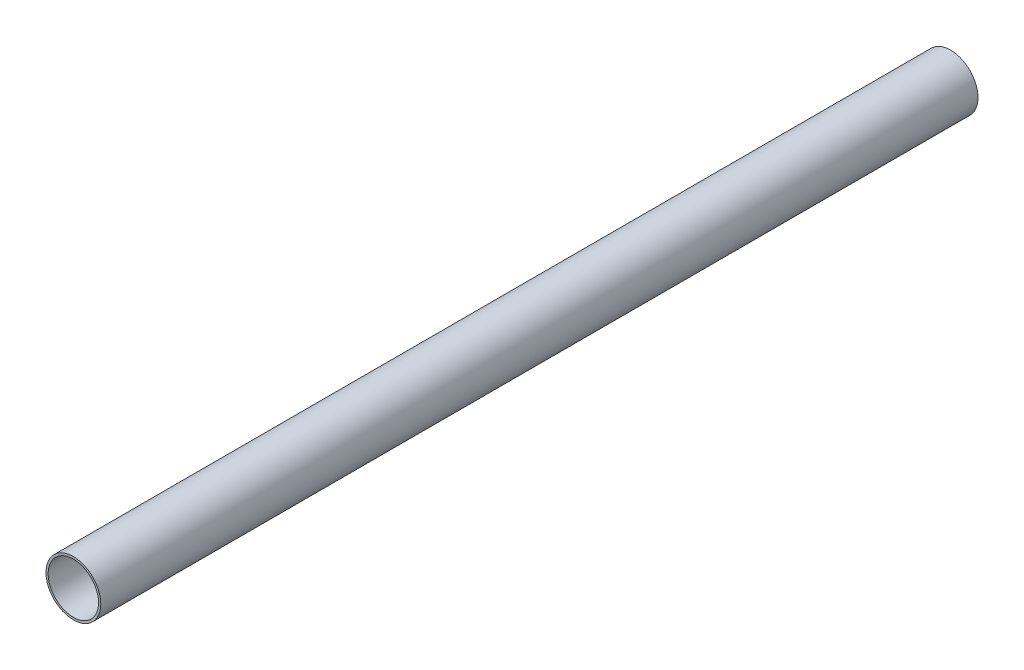
from build123d import *

# Parameters (mm, degrees)
SKETCH1_R           = 12.5
SKETCH1_R_2         = 11.5
BOSS_EXTRUDE1_DEPTH = 200


with BuildPart() as part:
    # Sketch1 → Boss-Extrude1 (new body, symmetric)
    with BuildSketch(Plane.XY):
        Circle(SKETCH1_R)
        Circle(SKETCH1_R_2, mode=Mode.SUBTRACT)
    extrude(amount=BOSS_EXTRUDE1_DEPTH, both=True)


solid = part.part
